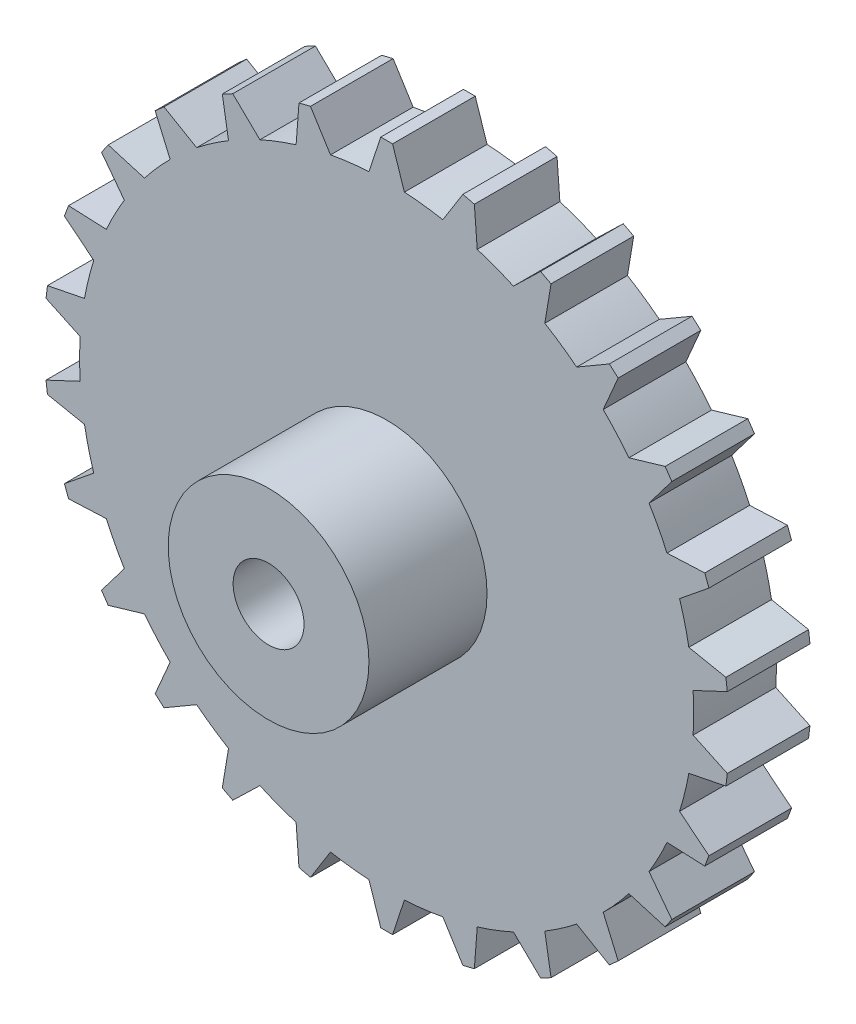
from build123d import *

# Parameters (mm, degrees)
SKETCH1_R                = 8.5
BOSS_EXTRUDE1_DEPTH      = 7
SKETCH2_R                = 8.5
SKETCH2_R_2              = 3
BOSS_EXTRUDE2_DEPTH      = 10
BOSS_EXTRUDE2_DEPTH_BACK = 7


with BuildPart() as part:
    # Sketch1 → Boss-Extrude1 (new body)
    with BuildSketch(Plane.XY):
        with BuildLine():
            Line((6.453651746, 28.272785132), (4.75543091, 25.561413828))
            ThreePointArc((4.75543091, 25.561413828), (3.133953687, 25.810430727), (1.5, 25.956694705))
            Line((1.5, 25.956694705), (0.5, 28.995689335))
            Line((0.5, 28.995689335), (-0.5, 28.995689335))
            Line((-0.5, 28.995689335), (-1.5, 25.956694705))
            ThreePointArc((-1.5, 25.956694705), (-3.133953687, 25.810430727), (-4.75543091, 25.561413828))
            Line((-4.75543091, 25.561413828), (-6.453651746, 28.272785132))
            Line((-6.453651746, 28.272785132), (-7.424593563, 28.033469468))
            Line((-7.424593563, 28.033469468), (-7.668256362, 24.843466835))
            ThreePointArc((-7.668256362, 24.843466835), (-9.219727063, 24.31042231), (-10.734493461, 23.680596491))
            Line((-10.734493461, 23.680596491), (-13.03224071, 25.906769425))
            Line((-13.03224071, 25.906769425), (-13.917696736, 25.442046253))
            Line((-13.917696736, 25.442046253), (-13.390861537, 22.286426974))
            ThreePointArc((-13.390861537, 22.286426974), (-14.769683415, 21.397580513), (-16.08970627, 20.423548961))
            Line((-16.08970627, 20.423548961), (-18.853443215, 22.035146447))
            Line((-18.853443215, 22.035146447), (-19.601953963, 21.372023789))
            Line((-19.601953963, 21.372023789), (-18.335238514, 18.434180986))
            ThreePointArc((-18.335238514, 18.434180986), (-19.461279452, 17.241189114), (-20.509843834, 15.979559002))
            Line((-20.509843834, 15.979559002), (-23.57895213, 16.882920851))
            Line((-23.57895213, 16.882920851), (-24.147016876, 16.059936985))
            Line((-24.147016876, 16.059936985), (-22.214038074, 13.510607405))
            ThreePointArc((-22.214038074, 13.510607405), (-23.021856667, 12.082802473), (-23.738023825, 10.606895158))
            Line((-23.738023825, 10.606895158), (-26.934138052, 10.749521263))
            Line((-26.934138052, 10.749521263), (-27.288742939, 9.81450502))
            Line((-27.288742939, 9.81450502), (-24.801838486, 7.80184643))
            ThreePointArc((-24.801838486, 7.80184643), (-25.244487253, 6.222207271), (-25.586636155, 4.617797121))
            Line((-25.586636155, 4.617797121), (-28.724009773, 3.991398571))
            Line((-28.724009773, 3.991398571), (-28.844546453, 2.998689697))
            Line((-28.844546453, 2.998689697), (-25.948246196, 1.639670499))
            ThreePointArc((-25.948246196, 1.639670499), (-26, 0), (-25.948246196, -1.639670499))
            Line((-25.948246196, -1.639670499), (-28.844546453, -2.998689697))
            Line((-28.844546453, -2.998689697), (-28.724009773, -3.991398571))
            Line((-28.724009773, -3.991398571), (-25.586636155, -4.617797121))
            ThreePointArc((-25.586636155, -4.617797121), (-25.244487253, -6.222207271), (-24.801838486, -7.80184643))
            Line((-24.801838486, -7.80184643), (-27.288742939, -9.81450502))
            Line((-27.288742939, -9.81450502), (-26.934138052, -10.749521263))
            Line((-26.934138052, -10.749521263), (-23.738023825, -10.606895158))
            ThreePointArc((-23.738023825, -10.606895158), (-23.021856667, -12.082802473), (-22.214038074, -13.510607405))
            Line((-22.214038074, -13.510607405), (-24.147016876, -16.059936985))
            Line((-24.147016876, -16.059936985), (-23.57895213, -16.882920851))
            Line((-23.57895213, -16.882920851), (-20.509843834, -15.979559002))
            ThreePointArc((-20.509843834, -15.979559002), (-19.461279452, -17.241189114), (-18.335238514, -18.434180986))
            Line((-18.335238514, -18.434180986), (-19.601953963, -21.372023789))
            Line((-19.601953963, -21.372023789), (-18.853443215, -22.035146447))
            Line((-18.853443215, -22.035146447), (-16.08970627, -20.423548961))
            ThreePointArc((-16.08970627, -20.423548961), (-14.769683415, -21.397580513), (-13.390861537, -22.286426974))
            Line((-13.390861537, -22.286426974), (-13.917696736, -25.442046253))
            Line((-13.917696736, -25.442046253), (-13.03224071, -25.906769425))
            Line((-13.03224071, -25.906769425), (-10.734493461, -23.680596491))
            ThreePointArc((-10.734493461, -23.680596491), (-9.219727063, -24.31042231), (-7.668256362, -24.843466835))
            Line((-7.668256362, -24.843466835), (-7.424593563, -28.033469468))
            Line((-7.424593563, -28.033469468), (-6.453651746, -28.272785132))
            Line((-6.453651746, -28.272785132), (-4.75543091, -25.561413828))
            ThreePointArc((-4.75543091, -25.561413828), (-3.133953687, -25.810430727), (-1.5, -25.956694705))
            Line((-1.5, -25.956694705), (-0.5, -28.995689335))
            Line((-0.5, -28.995689335), (0.5, -28.995689335))
            Line((0.5, -28.995689335), (1.5, -25.956694705))
            ThreePointArc((1.5, -25.956694705), (3.133953687, -25.810430727), (4.75543091, -25.561413828))
            Line((4.75543091, -25.561413828), (6.453651746, -28.272785132))
            Line((6.453651746, -28.272785132), (7.424593563, -28.033469468))
            Line((7.424593563, -28.033469468), (7.668256362, -24.843466835))
            ThreePointArc((7.668256362, -24.843466835), (9.219727063, -24.31042231), (10.734493461, -23.680596491))
            Line((10.734493461, -23.680596491), (13.03224071, -25.906769425))
            Line((13.03224071, -25.906769425), (13.917696736, -25.442046253))
            Line((13.917696736, -25.442046253), (13.390861537, -22.286426974))
            ThreePointArc((13.390861537, -22.286426974), (14.769683415, -21.397580513), (16.08970627, -20.423548961))
            Line((16.08970627, -20.423548961), (18.853443215, -22.035146447))
            Line((18.853443215, -22.035146447), (19.601953963, -21.372023789))
            Line((19.601953963, -21.372023789), (18.335238514, -18.434180986))
            ThreePointArc((18.335238514, -18.434180986), (19.461279452, -17.241189114), (20.509843834, -15.979559002))
            Line((20.509843834, -15.979559002), (23.57895213, -16.882920851))
            Line((23.57895213, -16.882920851), (24.147016876, -16.059936985))
            Line((24.147016876, -16.059936985), (22.214038074, -13.510607405))
            ThreePointArc((22.214038074, -13.510607405), (23.021856667, -12.082802473), (23.738023825, -10.606895158))
            Line((23.738023825, -10.606895158), (26.934138052, -10.749521263))
            Line((26.934138052, -10.749521263), (27.288742939, -9.81450502))
            Line((27.288742939, -9.81450502), (24.801838486, -7.80184643))
            ThreePointArc((24.801838486, -7.80184643), (25.244487253, -6.222207271), (25.586636155, -4.617797121))
            Line((25.586636155, -4.617797121), (28.724009773, -3.991398571))
            Line((28.724009773, -3.991398571), (28.844546453, -2.998689697))
            Line((28.844546453, -2.998689697), (25.948246196, -1.639670499))
            ThreePointArc((25.948246196, -1.639670499), (26, 0), (25.948246196, 1.639670499))
            Line((25.948246196, 1.639670499), (28.844546453, 2.998689697))
            Line((28.844546453, 2.998689697), (28.724009773, 3.991398571))
            Line((28.724009773, 3.991398571), (25.586636155, 4.617797121))
            ThreePointArc((25.586636155, 4.617797121), (25.244487253, 6.222207271), (24.801838486, 7.80184643))
            Line((24.801838486, 7.80184643), (27.288742939, 9.81450502))
            Line((27.288742939, 9.81450502), (26.934138052, 10.749521263))
            Line((26.934138052, 10.749521263), (23.738023825, 10.606895158))
            ThreePointArc((23.738023825, 10.606895158), (23.021856667, 12.082802473), (22.214038074, 13.510607405))
            Line((22.214038074, 13.510607405), (24.147016876, 16.059936985))
            Line((24.147016876, 16.059936985), (23.57895213, 16.882920851))
            Line((23.57895213, 16.882920851), (20.509843834, 15.979559002))
            ThreePointArc((20.509843834, 15.979559002), (19.461279452, 17.241189114), (18.335238514, 18.434180986))
            Line((18.335238514, 18.434180986), (19.601953963, 21.372023789))
            Line((19.601953963, 21.372023789), (18.853443215, 22.035146447))
            Line((18.853443215, 22.035146447), (16.08970627, 20.423548961))
            ThreePointArc((16.08970627, 20.423548961), (14.769683415, 21.397580513), (13.390861537, 22.286426974))
            Line((13.390861537, 22.286426974), (13.917696736, 25.442046253))
            Line((13.917696736, 25.442046253), (13.03224071, 25.906769425))
            Line((13.03224071, 25.906769425), (10.734493461, 23.680596491))
            ThreePointArc((10.734493461, 23.680596491), (9.219727063, 24.31042231), (7.668256362, 24.843466835))
            Line((7.668256362, 24.843466835), (7.424593563, 28.033469468))
            Line((7.424593563, 28.033469468), (6.453651746, 28.272785132))
        make_face()
        Circle(SKETCH1_R, mode=Mode.SUBTRACT)
    extrude(amount=BOSS_EXTRUDE1_DEPTH)

    # Sketch2 → Boss-Extrude2 (add, two sides)
    with BuildSketch(Plane.XY.offset(7)) as boss_extrude2_sk:
        Circle(SKETCH2_R)
        Circle(SKETCH2_R_2, mode=Mode.SUBTRACT)
    extrude(amount=BOSS_EXTRUDE2_DEPTH)
    extrude(boss_extrude2_sk.sketch, amount=-BOSS_EXTRUDE2_DEPTH_BACK)


solid = part.part
